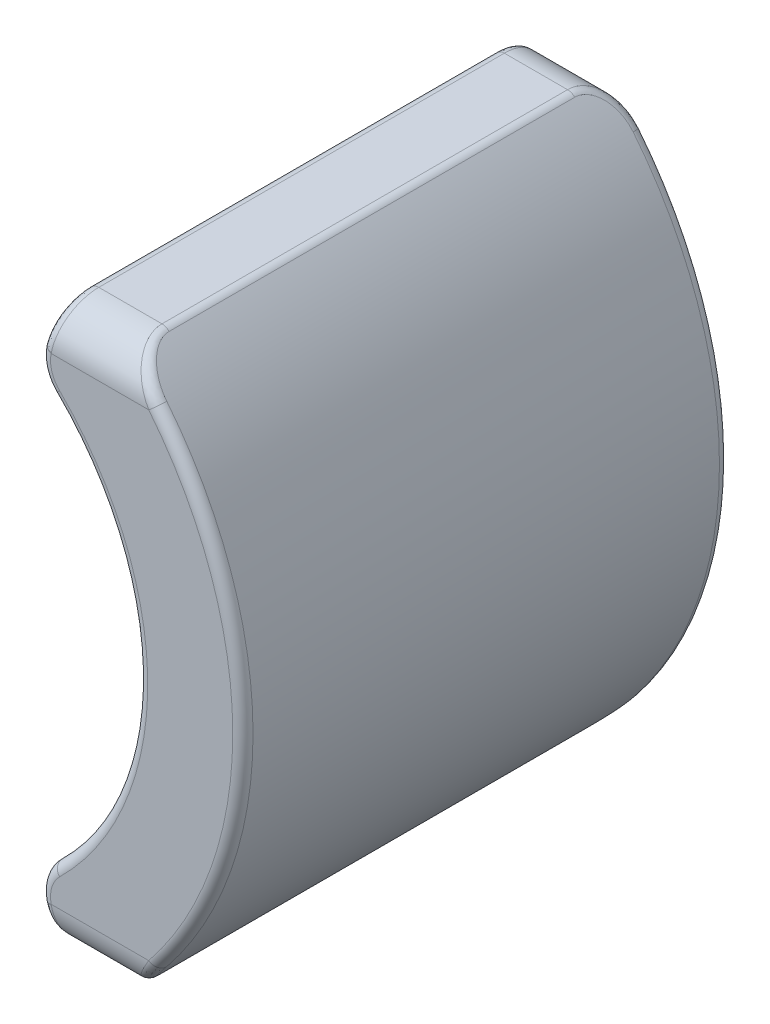
from build123d import *

# Parameters (mm, degrees)
BOSS_EXTRUDE1_DEPTH = 12
FILLET1_R           = 1
FILLET3_R           = 1
FILLET4_R           = 1
FILLET5_R           = 1
FILLET6_R           = 0.25


with BuildPart() as part:
    # Sketch1 → Boss-Extrude1 (new body)
    with BuildSketch(Plane.XY):
        with BuildLine():
            Line((5.123968755, -6.88), (3.263968755, -6.88))
            Line((3.263968755, -6.88), (2.917666468, -5.38))
            ThreePointArc((2.917666468, -5.38), (5.420170547, 0), (2.917666468, 5.38))
            Line((2.917666468, 5.38), (3.263968755, 6.88))
            Line((3.263968755, 6.88), (5.123968755, 6.88))
            ThreePointArc((5.123968755, 6.88), (8.01583103, 0), (5.123968755, -6.88))
        make_face()
    extrude(amount=BOSS_EXTRUDE1_DEPTH)

    # Fillet1
    fillet1_edges = [part.edges().sort_by_distance(p)[0] for p in [
        (2.917666468, -5.38, 6),
        (2.917666468, 5.38, 6),
    ]]
    fillet(fillet1_edges, radius=FILLET1_R)

    # Fillet3
    fillet3_edges = [part.edges().sort_by_distance(p)[0] for p in [
        (4.193968755, 6.88, 0),
    ]]
    fillet(fillet3_edges, radius=FILLET3_R)

    # Fillet4
    fillet4_edges = [part.edges().sort_by_distance(p)[0] for p in [
        (4.193968755, -6.88, 0),
    ]]
    fillet(fillet4_edges, radius=FILLET4_R)

    # Fillet5
    fillet5_edges = [part.edges().sort_by_distance(p)[0] for p in [
        (4.193968755, 6.88, 12),
        (4.193968755, -6.88, 12),
    ]]
    fillet(fillet5_edges, radius=FILLET5_R)

    # Fillet6
    fillet6_edges = [part.edges().sort_by_distance(p)[0] for p in [
        (5.420170547, 0, 0),
        (3.073708296, 5.411310183, 0),
        (5.420170547, 0, 12),
        (3.073708296, -5.411310183, 12),
        (3.200954518, 6.607055355, 0.313421155),
        (3.041765805, 5.914769544, 0.00060465),
        (5.450167616, 6.544619823, 0.252818297),
        (8.01583103, 0, 0),
        (5.450167607, -6.544619807, 0.2528183),
        (3.073708296, -5.411310183, 0),
        (3.041765802, -5.914769545, 0.000604643),
        (3.200954518, -6.607055355, 0.313421155),
        (8.01583103, 0, 12),
        (3.073708296, 5.411310183, 12),
        (3.041765805, 5.914769544, 11.99939535),
        (3.263968755, 6.88, 6),
        (3.200954518, 6.607055355, 11.686578845),
        (5.123968755, 6.88, 6),
        (5.123968755, -6.88, 6),
        (5.450167618, -6.544619821, 11.747181705),
        (5.450167616, 6.544619824, 11.747181702),
        (3.263968755, -6.88, 6),
        (3.200954518, -6.607055355, 11.686578845),
        (3.041765802, -5.914769545, 11.999395357),
    ]]
    fillet(fillet6_edges, radius=FILLET6_R)


solid = part.part
